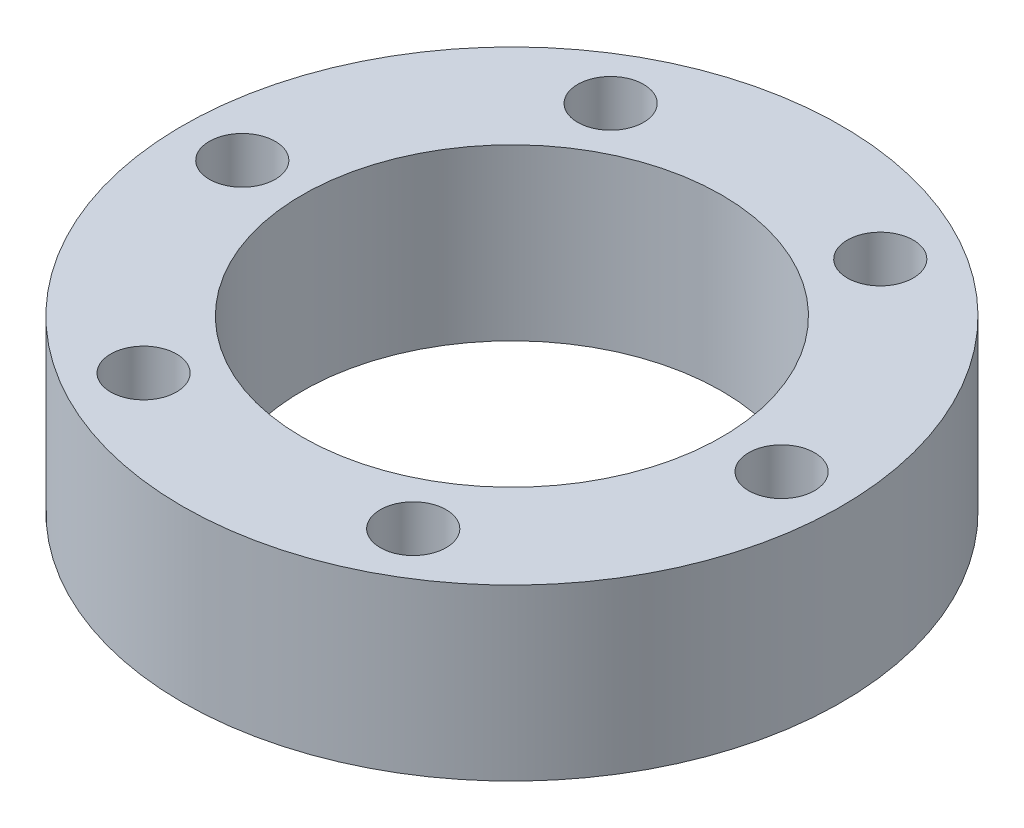
from build123d import *

# Parameters (mm, degrees)
SKETCH1_R                = 33
SKETCH1_R_2              = 21
BOSS_EXTRUDE1_DEPTH      = 17
M6_CLEARANCE_HOLE1_D     = 6.6
M6_CLEARANCE_HOLE1_DEPTH = 17
CIRPATTERN1_COUNT        = 6


with BuildPart() as part:
    # Sketch1 → Boss-Extrude1 (new body)
    with BuildSketch(Plane(origin=(0, 0, 0), x_dir=(1, 0, 0), z_dir=(0, 1, 0))):
        Circle(SKETCH1_R)
        Circle(SKETCH1_R_2, mode=Mode.SUBTRACT)
    extrude(amount=BOSS_EXTRUDE1_DEPTH)

    # M6 Clearance Hole1
    with Locations(Plane(origin=(-27, 17, 0), x_dir=(0, 0, 1), z_dir=(0, 1, 0))):
        with Locations((0, 0)):
            m6_clearance_hole1 = Hole(M6_CLEARANCE_HOLE1_D / 2, depth=M6_CLEARANCE_HOLE1_DEPTH)

    # CirPattern1: M6 Clearance Hole1 ×6 about axis
    cirpattern1_axis = Axis((0, 0, 0), (0, 1, 0))
    for i in range(1, CIRPATTERN1_COUNT):
        add(m6_clearance_hole1.rotate(cirpattern1_axis, i * 360 / CIRPATTERN1_COUNT), mode=Mode.SUBTRACT)


solid = part.part
